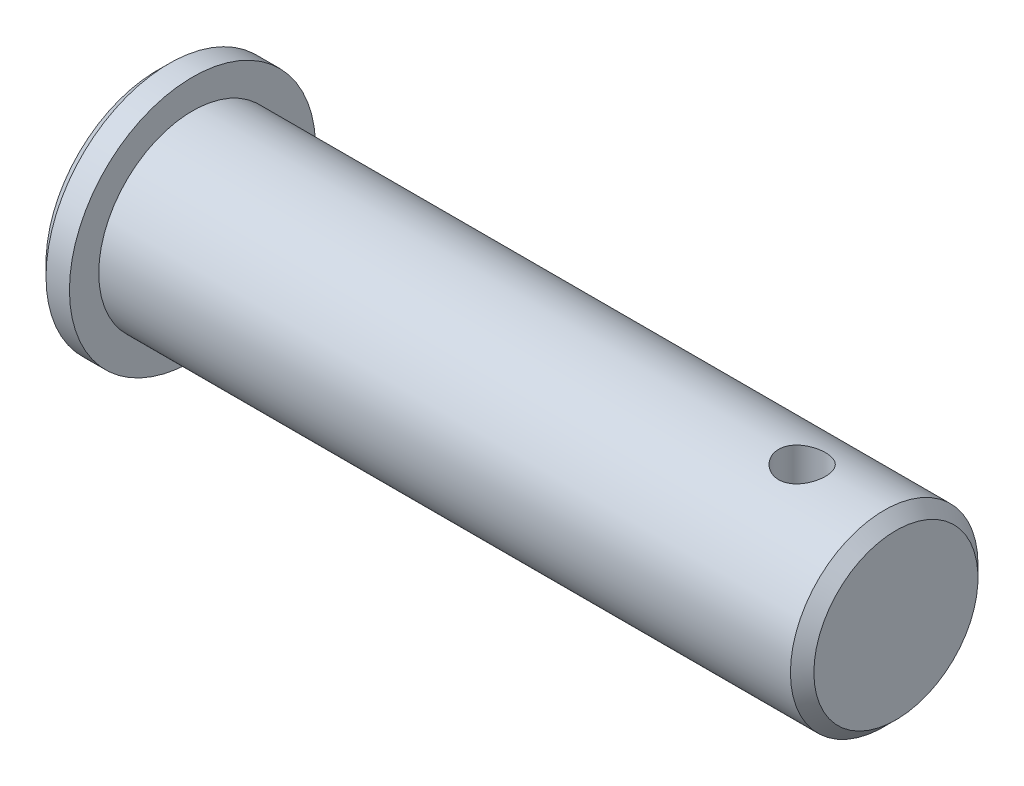
from build123d import *

# Parameters (mm, degrees)
SFAZOWANIE2_SIZE                = 1
SZKIC2_R                        = 2
WYTNIJ_WYCI_GNI_CIE1_DEPTH      = 11.5
WYTNIJ_WYCI_GNI_CIE1_DEPTH_BACK = 11.5


with BuildPart() as part:
    # Szkic1 → Obrót1 (revolve)
    with BuildSketch(Plane.XY):
        Polygon((0, 0), (0, 10.5), (3, 10.5), (3, 8), (63, 8), (63, 0), align=None)
    revolve(axis=Axis((0, 0, 0), (1, 0, 0)))

    # Sfazowanie2
    sfazowanie2_edges = [part.edges().sort_by_distance(p)[0] for p in [
        (0, -10.5, 0),
        (63, -8, 0),
    ]]
    chamfer(sfazowanie2_edges, length=SFAZOWANIE2_SIZE)

    # Szkic2 → Wytnij-wyciągnięcie1 (cut, two sides)
    with BuildSketch(Plane(origin=(0, 0, 0), x_dir=(1, 0, 0), z_dir=(0, 1, 0))) as wytnij_wyci_gni_cie1_sk:
        with Locations((55, 0)):
            Circle(SZKIC2_R)
    extrude(amount=WYTNIJ_WYCI_GNI_CIE1_DEPTH, mode=Mode.SUBTRACT)
    extrude(wytnij_wyci_gni_cie1_sk.sketch, amount=-WYTNIJ_WYCI_GNI_CIE1_DEPTH_BACK, mode=Mode.SUBTRACT)


solid = part.part
